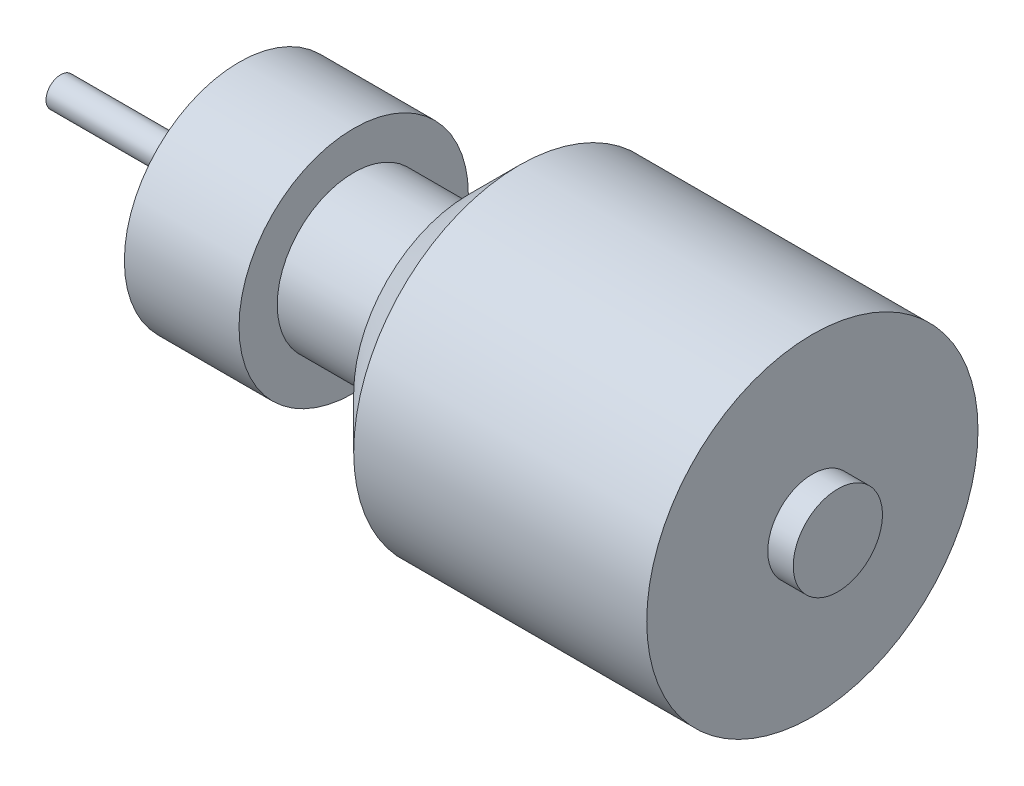
from build123d import *

# Parameters (mm, degrees)
TROU_TARAUD_M2X0_41_D           = 1.6
TROU_TARAUD_M2X0_41_DEPTH       = 6
TROU_TARAUD_M2X0_41_CSINK_D     = 2.05
TROU_TARAUD_M2X0_41_CSINK_ANGLE = 90
TROU_TARAUD_M2X0_41_TIP         = 0.480688495


with BuildPart() as part:
    # Esquisse1 → Révolution1 (revolve)
    with BuildSketch(Plane.XY):
        Polygon((-14, 1.15), (0, 1.15), (0, 9), (9, 9), (9, 6), (18, 6), (18, 9), (22, 13), (45, 13), (45, 3.5), (47, 3.5), (47, 0), (-14, 0), align=None)
    revolve(axis=Axis((-25.880121982, 0, 0), (1, 0, 0)))

    # Trou taraudé M2x0.41
    with Locations(Plane.ZY):
        with Locations((0, 5.164935058), (5.164935058, 0), (0, -5.164935058), (-5.164935058, 0)):
            CounterSinkHole(TROU_TARAUD_M2X0_41_D / 2, TROU_TARAUD_M2X0_41_CSINK_D / 2, depth=TROU_TARAUD_M2X0_41_DEPTH, counter_sink_angle=TROU_TARAUD_M2X0_41_CSINK_ANGLE)
            with Locations((0, 0, -(TROU_TARAUD_M2X0_41_DEPTH + TROU_TARAUD_M2X0_41_TIP / 2))):  # 118° drill point
                Cone(0, TROU_TARAUD_M2X0_41_D / 2, TROU_TARAUD_M2X0_41_TIP, mode=Mode.SUBTRACT)


solid = part.part
